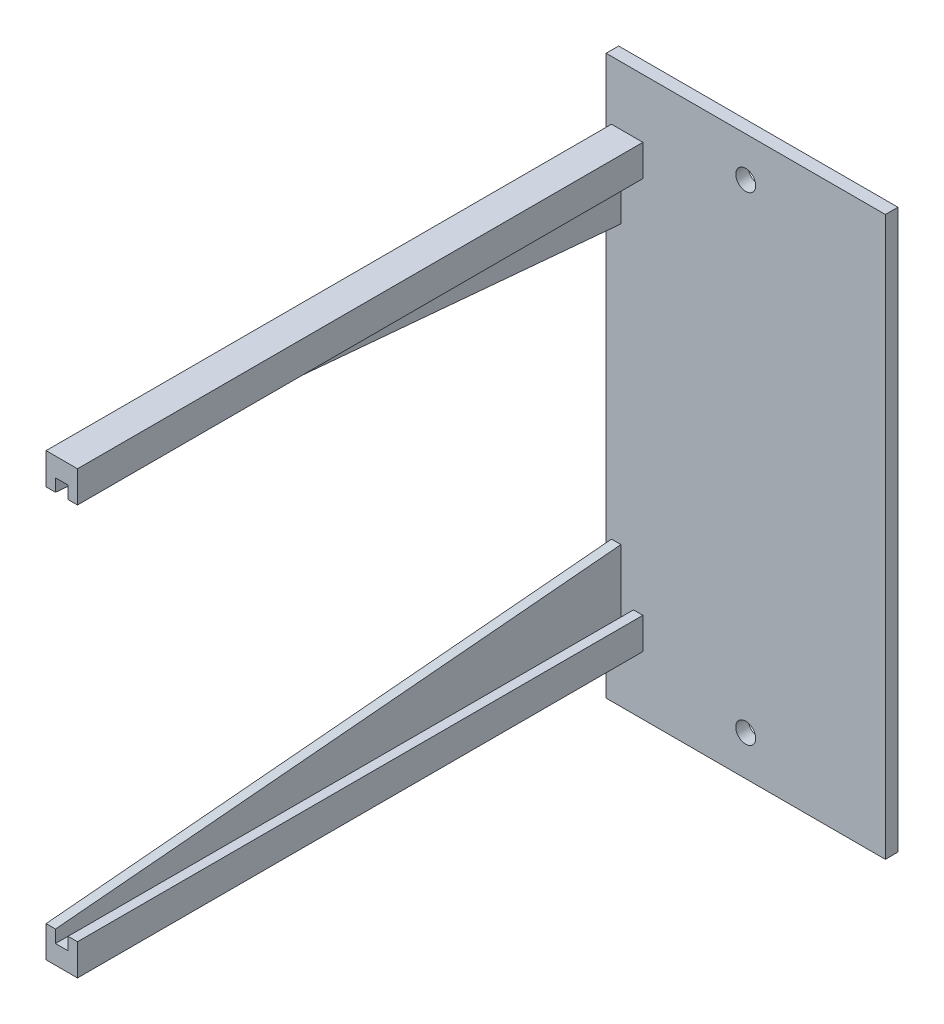
from build123d import *

# Parameters (mm, degrees)
FRONT_FACE_W        = 44.45
FRONT_FACE_H        = 88.9
FRONT_FACE_R        = 1.5875
BOSS_EXTRUDE1_DEPTH = 2
CANTIARM_W          = 90
CANTIARM_H          = 5
BOSS_EXTRUDE2_DEPTH = 2.5
CHANNEL_W           = 2
CHANNEL_H           = 2
CUT_EXTRUDE1_DEPTH  = 91
BOSS_EXTRUDE5_START = 1
BOSS_EXTRUDE5_DEPTH = 1.5


with BuildPart() as part:
    # Front Face → Boss-Extrude1 (new body)
    with BuildSketch(Plane.XY):
        Rectangle(FRONT_FACE_W, FRONT_FACE_H)
        with Locations((0, 38.1)):
            Circle(FRONT_FACE_R, mode=Mode.SUBTRACT)
        with Locations((0, -38.1)):
            Circle(FRONT_FACE_R, mode=Mode.SUBTRACT)
    extrude(amount=BOSS_EXTRUDE1_DEPTH)

    # CantiArm → Boss-Extrude2 (add, symmetric)
    with BuildSketch(Plane.ZY.offset(18.868316672)):
        with Locations((47, 32.6)):
            Rectangle(CANTIARM_W, CANTIARM_H)
    boss_extrude2 = extrude(amount=BOSS_EXTRUDE2_DEPTH, both=True)

    # Channel → Cut-Extrude1 (cut, through all)
    with BuildSketch(Plane.XY.offset(2)):
        with Locations((-18.868316672, 31.1)):
            Rectangle(CHANNEL_W, CHANNEL_H)
    cut_extrude1 = extrude(amount=CUT_EXTRUDE1_DEPTH, mode=Mode.SUBTRACT)

    # Sketch5 → Boss-Extrude5 (add)
    with BuildSketch(Plane.ZY.offset(18.868316672).offset(BOSS_EXTRUDE5_START)):
        Polygon((2, 22.1), (92, 30.1), (2, 30.1), align=None)
    boss_extrude5 = extrude(amount=BOSS_EXTRUDE5_DEPTH)

    # Mirror1: Boss-Extrude2, Cut-Extrude1, Boss-Extrude5 across plane
    add(boss_extrude2.mirror(Plane.ZX))
    add(cut_extrude1.mirror(Plane.ZX), mode=Mode.SUBTRACT)
    add(boss_extrude5.mirror(Plane.ZX))


solid = part.part
